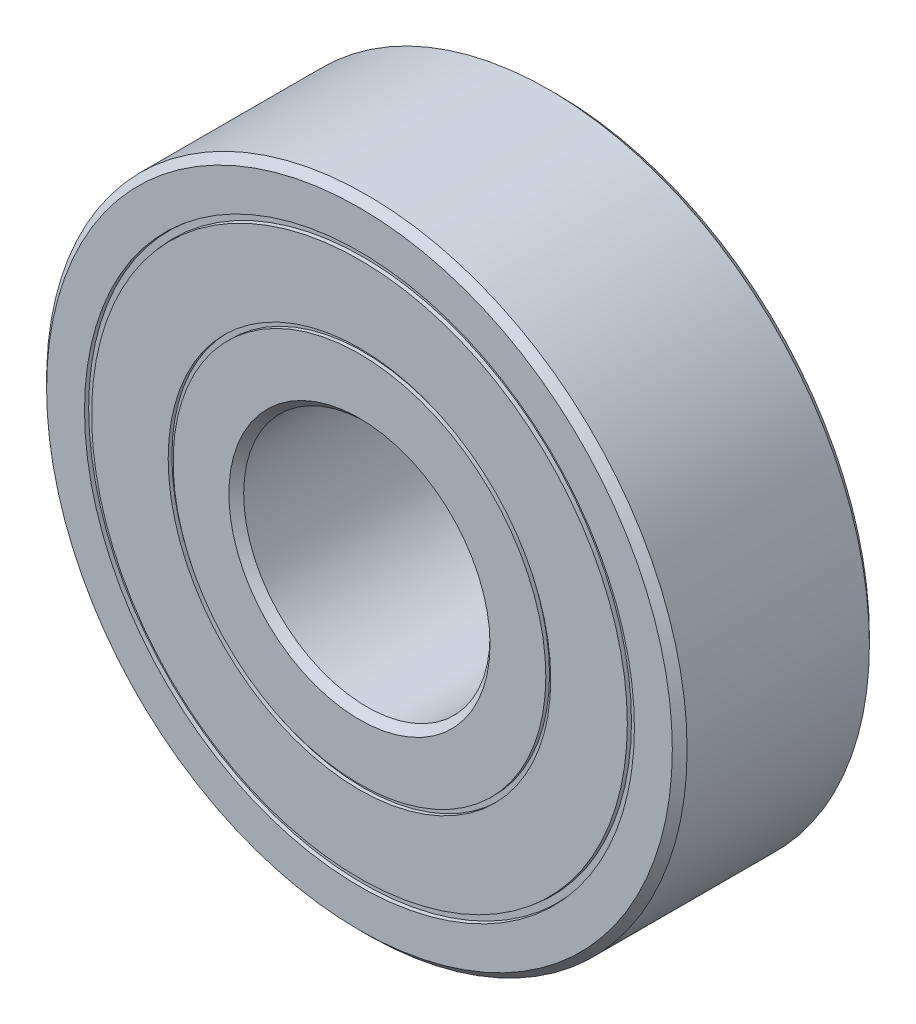
from build123d import *

# Parameters (mm, degrees)
CROQUIS1_R              = 13
CROQUIS1_R_2            = 5
SALIENTE_EXTRUIR1_DEPTH = 8
CHAFL_N1_SIZE           = 0.3
CROQUIS2_W              = 1
CROQUIS2_H              = 0.2


with BuildPart() as part:
    # Croquis1 → Saliente-Extruir1 (new body)
    with BuildSketch(Plane.XY):
        Circle(CROQUIS1_R)
        Circle(CROQUIS1_R_2, mode=Mode.SUBTRACT)
    extrude(amount=SALIENTE_EXTRUIR1_DEPTH)

    # Chaflán1
    chafl_n1_edges = [part.edges().sort_by_distance(p)[0] for p in [
        (-13, 0, 0),
        (-13, 0, 8),
        (-5, 0, 0),
        (-5, 0, 8),
    ]]
    chamfer(chafl_n1_edges, length=CHAFL_N1_SIZE)

    # Croquis2 → Cortar-Revolución1 (revolve, cut)
    with BuildSketch(Plane(origin=(0, 0, 0), x_dir=(0, 0, -1), z_dir=(1, 0, 0))):
        Polygon((-8.85, 11.267505128), (-7.85, 11.142505128), (-7.85, 10.892505128), (-8.85, 10.767505128), align=None)
        Polygon((0.85, 10.767505128), (0.85, 11.267505128), (-0.15, 11.142505128), (-0.15, 10.892505128), align=None)
        with Locations((-8.35, 7.665073065)):
            Rectangle(CROQUIS2_W, CROQUIS2_H)
        with Locations((0.35, 7.665073065)):
            Rectangle(CROQUIS2_W, CROQUIS2_H)
    revolve(axis=Axis((0, 0, 12.411349243), (0, 0, -1)), mode=Mode.SUBTRACT)


solid = part.part
